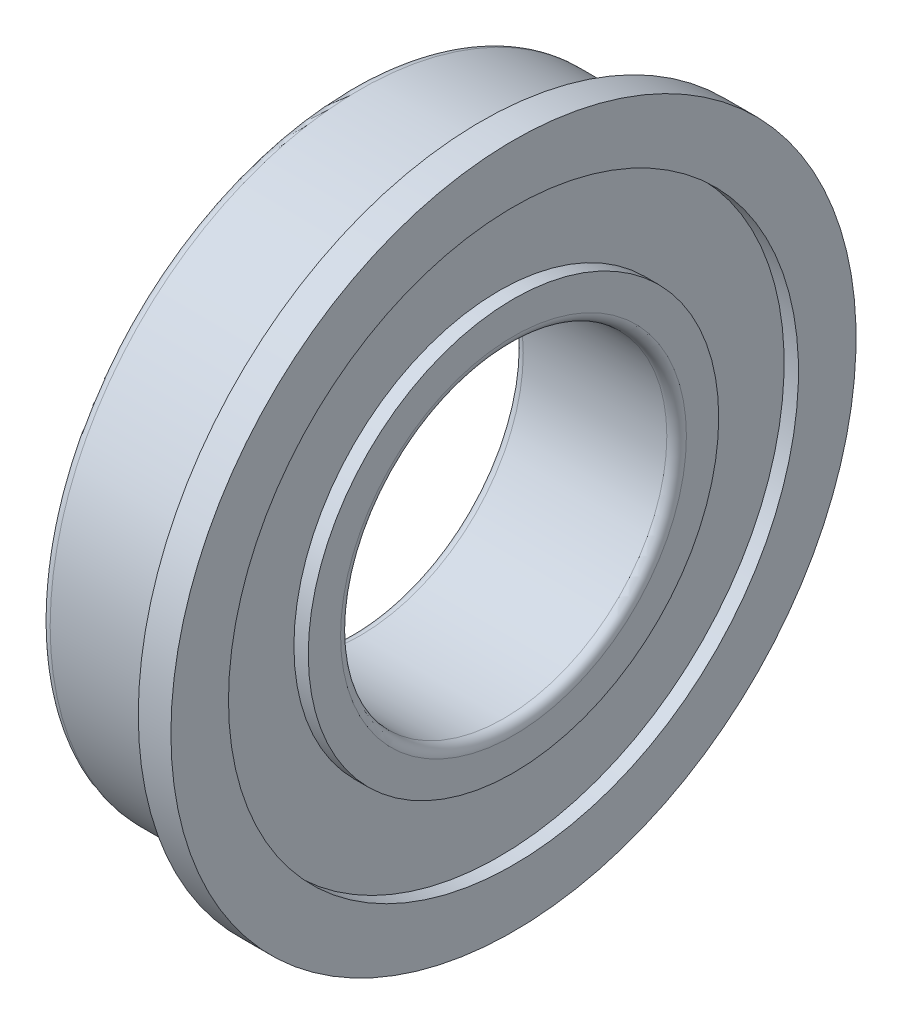
from build123d import *

# Parameters (mm, degrees)
FILLET1_R = 0.3


with BuildPart() as part:
    # Sketch1 → Revolve1 (revolve)
    with BuildSketch(Plane.XY):
        with BuildLine():
            Line((0, 9.7), (0, 10.5))
            Line((0, 10.5), (1, 10.5))
            Line((1, 10.5), (1, 8.735))
            Line((1, 8.735), (0.56, 8.735))
            Line((0.56, 8.735), (0.56, 6.29))
            Line((0.56, 6.29), (1, 6.29))
            Line((1, 6.29), (1, 5))
            Line((1, 5), (-4, 5))
            Line((-4, 5), (-4, 6.29))
            Line((-4, 6.29), (-3.56, 6.29))
            Line((-3.56, 6.29), (-3.56, 8.735))
            Line((-3.56, 8.735), (-4, 8.735))
            Line((-4, 8.735), (-4, 9.5))
            Line((-4, 9.5), (-0.2, 9.5))
            ThreePointArc((-0.2, 9.5), (0.141421356, 9.358578644), (0, 9.7))
        make_face()
    revolve(axis=Axis((-4, 0, 0), (1, 0, 0)))

    # Fillet1
    fillet1_edges = [part.edges().sort_by_distance(p)[0] for p in [
        (1, -5, 0),
        (-4, -5, 0),
        (-4, -9.5, 0),
    ]]
    fillet(fillet1_edges, radius=FILLET1_R)


solid = part.part
